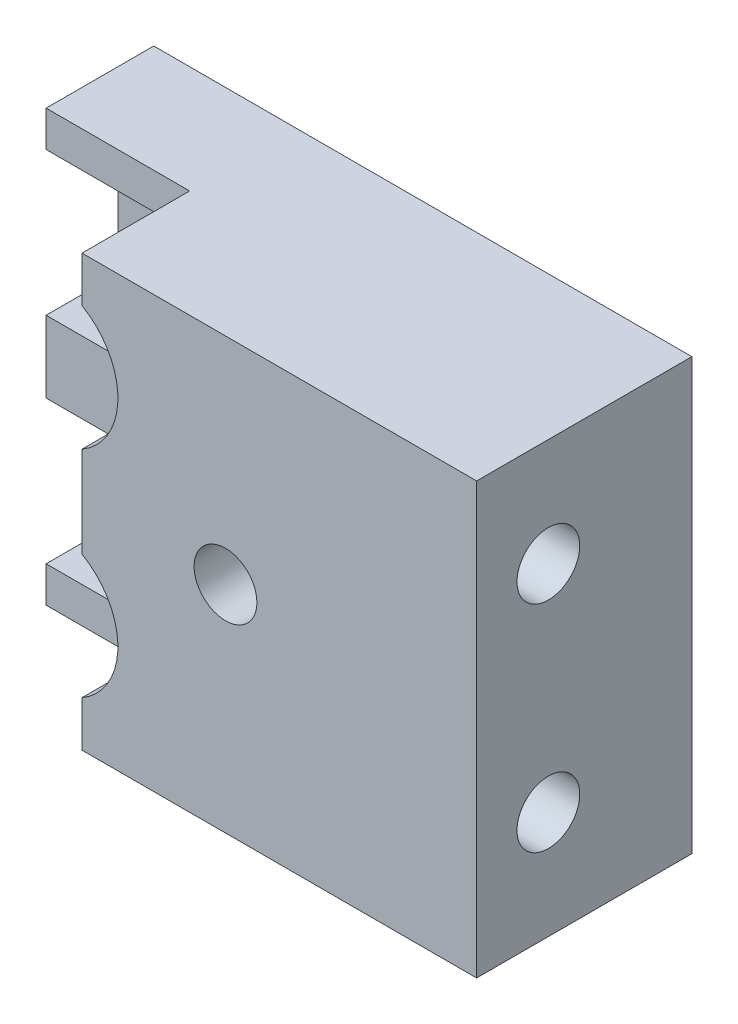
from build123d import *

# Parameters (mm, degrees)
SKETCH1_W              = 150
SKETCH1_H              = 120
BOSS_EXTRUDE1_DEPTH    = 60
SKETCH2_W              = 10
SKETCH2_H              = 40
CUT_EXTRUDE1_DEPTH     = 60
CUT_EXTRUDE2_DEPTH     = 40
M20_TAPPED_HOLE1_D     = 17.5
M20_TAPPED_HOLE1_DEPTH = 67.5
M20_TAPPED_HOLE1_TIP   = 5.257530416
CUT_EXTRUDE4_DEPTH     = 30
M20_TAPPED_HOLE2_D     = 17.5
M20_TAPPED_HOLE2_DEPTH = 30
M20_TAPPED_HOLE2_TIP   = 5.257530416
M20_TAPPED_HOLE3_D     = 17.5
M20_TAPPED_HOLE3_DEPTH = 35
M20_TAPPED_HOLE3_TIP   = 5.257530416


with BuildPart() as part:
    # Sketch1 → Boss-Extrude1 (new body)
    with BuildSketch(Plane.XY):
        with Locations((75, 60)):
            Rectangle(SKETCH1_W, SKETCH1_H)
    extrude(amount=BOSS_EXTRUDE1_DEPTH)

    # Sketch2 → Cut-Extrude1 (cut)
    with BuildSketch(Plane.XY.offset(60)):
        with Locations((5, 90)):
            Rectangle(SKETCH2_W, SKETCH2_H)
        with Locations((5, 30)):
            Rectangle(SKETCH2_W, SKETCH2_H)
    extrude(amount=-CUT_EXTRUDE1_DEPTH, mode=Mode.SUBTRACT)

    # Sketch3 → Cut-Extrude2 (cut)
    with BuildSketch(Plane.XY.offset(60)):
        with BuildLine():
            Line((10, 110), (30, 110))
            ThreePointArc((30, 110), (50, 90), (30, 70))
            Line((30, 70), (10, 70))
            Line((10, 70), (10, 110))
        make_face()
        with BuildLine():
            Line((10, 50), (10, 10))
            Line((10, 10), (30, 10))
            ThreePointArc((30, 10), (50, 30), (30, 50))
            Line((30, 50), (10, 50))
        make_face()
    extrude(amount=-CUT_EXTRUDE2_DEPTH, mode=Mode.SUBTRACT)

    # M20 Tapped Hole1
    with Locations(Plane(origin=(30, 90, 20), x_dir=(1, 0, 0), z_dir=(0, 0, 1))):
        with Locations((0, 0), (0, -60)):
            Hole(M20_TAPPED_HOLE1_D / 2, depth=M20_TAPPED_HOLE1_DEPTH)
            with Locations((0, 0, -(M20_TAPPED_HOLE1_DEPTH + M20_TAPPED_HOLE1_TIP / 2))):  # 118° drill point
                Cone(0, M20_TAPPED_HOLE1_D / 2, M20_TAPPED_HOLE1_TIP, mode=Mode.SUBTRACT)

    # Sketch6 → Cut-Extrude4 (cut)
    with BuildSketch(Plane.XY.offset(60)):
        with BuildLine():
            ThreePointArc((30, 110), (35.176380902, 109.318516526), (40, 107.320508076))
            Line((40, 107.320508076), (40, 120))
            Line((40, 120), (0, 120))
            Line((0, 120), (0, 110))
            Line((0, 110), (30, 110))
        make_face()
        with BuildLine():
            Line((40, 47.320508076), (40, 72.679491924))
            ThreePointArc((40, 72.679491924), (35.176380902, 70.681483474), (30, 70))
            Line((30, 70), (0, 70))
            Line((0, 70), (0, 50))
            Line((0, 50), (30, 50))
            ThreePointArc((30, 50), (35.176380902, 49.318516526), (40, 47.320508076))
        make_face()
        with BuildLine():
            Line((40, 0), (40, 12.679491924))
            ThreePointArc((40, 12.679491924), (35.176380902, 10.681483474), (30, 10))
            Line((30, 10), (0, 10))
            Line((0, 10), (0, 0))
            Line((0, 0), (40, 0))
        make_face()
    extrude(amount=-CUT_EXTRUDE4_DEPTH, mode=Mode.SUBTRACT)

    # M20 Tapped Hole2
    with Locations(Plane(origin=(80, 60, 60), x_dir=(1, 0, 0), z_dir=(0, 0, 1))):
        with Locations((0, 0)):
            Hole(M20_TAPPED_HOLE2_D / 2, depth=M20_TAPPED_HOLE2_DEPTH)
            with Locations((0, 0, -(M20_TAPPED_HOLE2_DEPTH + M20_TAPPED_HOLE2_TIP / 2))):  # 118° drill point
                Cone(0, M20_TAPPED_HOLE2_D / 2, M20_TAPPED_HOLE2_TIP, mode=Mode.SUBTRACT)

    # M20 Tapped Hole3
    with Locations(Plane(origin=(150, 90, 40), x_dir=(0, 0, 1), z_dir=(1, 0, 0))):
        with Locations((0, 0), (0, 60)):
            Hole(M20_TAPPED_HOLE3_D / 2, depth=M20_TAPPED_HOLE3_DEPTH)
            with Locations((0, 0, -(M20_TAPPED_HOLE3_DEPTH + M20_TAPPED_HOLE3_TIP / 2))):  # 118° drill point
                Cone(0, M20_TAPPED_HOLE3_D / 2, M20_TAPPED_HOLE3_TIP, mode=Mode.SUBTRACT)


solid = part.part
